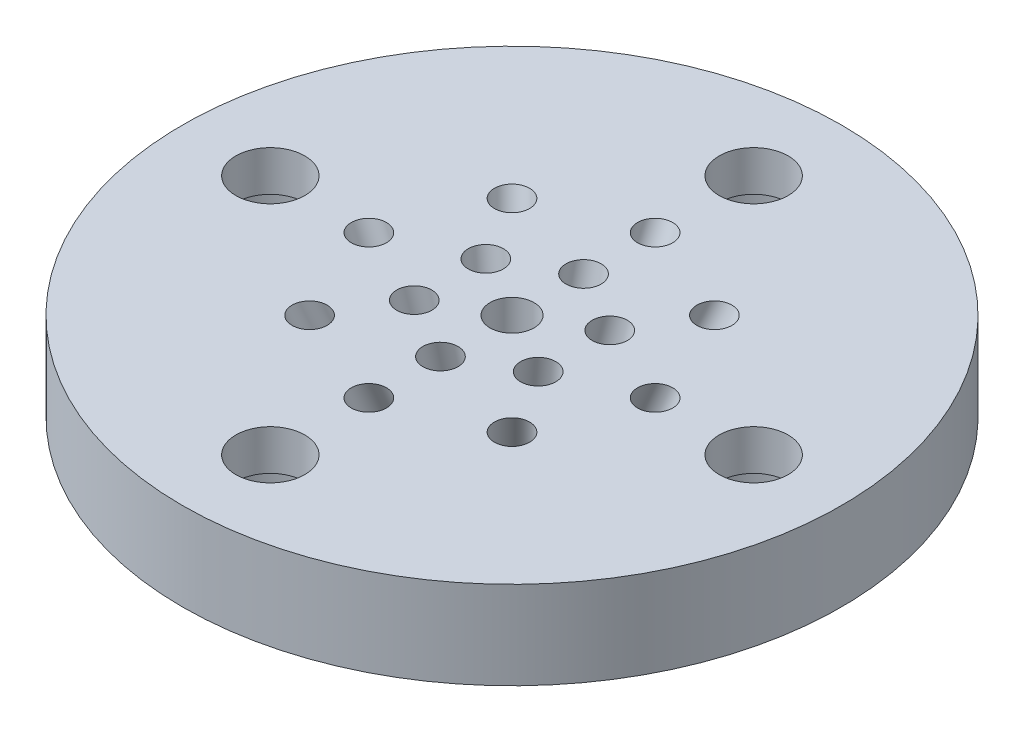
from build123d import *

# Parameters (mm, degrees)
SKETCH1_R                                           = 50.8
BOSS_EXTRUDE1_DEPTH                                 = 25.4
SKETCH2_R                                           = 69.85
SKETCH2_R_2                                         = 50.8
BOSS_EXTRUDE2_DEPTH                                 = 12.7
SKETCH3_R                                           = 49.53
SKETCH3_R_2                                         = 47.625
CUT_EXTRUDE1_DEPTH                                  = 1.1176
CUT_EXTRUDE2_REACH                                  = 103.996
SKETCH4_R                                           = 3.175
SKETCH5_R                                           = 11.43
CUT_EXTRUDE3_DEPTH                                  = 19.05
CUT_EXTRUDE4_REACH                                  = 102.603
SKETCH6_R                                           = 1.5875
SKETCH42_OUTSIDE_W                                  = 181.538
SKETCH42_OUTSIDE_H                                  = 181.538
SKETCH42_OUTSIDE_R                                  = 23.8125
CUT_EXTRUDE9_DEPTH                                  = 30.48
SKETCH43_R                                          = 20.6375
CUT_EXTRUDE10_DEPTH                                 = 19.05
CBORE_FOR_10_BINDING_HEAD_MACHINE_SCREW_D           = 4.9784
CBORE_FOR_10_BINDING_HEAD_MACHINE_SCREW_CBORE_D     = 9.525
CBORE_FOR_10_BINDING_HEAD_MACHINE_SCREW_CBORE_DEPTH = 3.429
CUT_EXTRUDE11_START                                 = -19.05
SKETCH52_R                                          = 23.8125
CUT_EXTRUDE11_DEPTH                                 = 19.05
SKETCH55_R                                          = 1.27
CUT_EXTRUDE12_DEPTH                                 = 7.62
CIRPATTERN1_COUNT                                   = 6
SKETCH57_R                                          = 1.27
CUT_EXTRUDE13_DEPTH                                 = 7.62
CIRPATTERN2_COUNT                                   = 8


with BuildPart() as part:
    # Sketch1 → Boss-Extrude1 (new body)
    with BuildSketch(Plane(origin=(0, 0, 0), x_dir=(1, 0, 0), z_dir=(0, 1, 0))):
        Circle(SKETCH1_R)
    extrude(amount=BOSS_EXTRUDE1_DEPTH)

    # Sketch2 → Boss-Extrude2 (add)
    with BuildSketch(Plane.XZ):
        Circle(SKETCH2_R)
        Circle(SKETCH2_R_2, mode=Mode.SUBTRACT)
    extrude(amount=-BOSS_EXTRUDE2_DEPTH)

    # Sketch3 → Cut-Extrude1 (cut)
    with BuildSketch(Plane.XZ):
        Circle(SKETCH3_R)
        Circle(SKETCH3_R_2, mode=Mode.SUBTRACT)
    extrude(amount=-CUT_EXTRUDE1_DEPTH, mode=Mode.SUBTRACT)

    # Sketch4 → Cut-Extrude2 (cut, up to next)
    with BuildSketch(Plane.XZ, mode=Mode.PRIVATE) as cut_extrude2_sk1:
        with Locations((0, -59.9186)):
            Circle(SKETCH4_R)
    cut_extrude2_tool1 = extrude(cut_extrude2_sk1.sketch, amount=-CUT_EXTRUDE2_REACH, mode=Mode.PRIVATE) & part.part
    # Sketch4 → Cut-Extrude2 (cut, up to next)
    with BuildSketch(Plane.XZ, mode=Mode.PRIVATE) as cut_extrude2_sk2:
        with Locations((-42.368848379, -42.368848379)):
            Circle(SKETCH4_R)
    cut_extrude2_tool2 = extrude(cut_extrude2_sk2.sketch, amount=-CUT_EXTRUDE2_REACH, mode=Mode.PRIVATE) & part.part
    # Sketch4 → Cut-Extrude2 (cut, up to next)
    with BuildSketch(Plane.XZ, mode=Mode.PRIVATE) as cut_extrude2_sk3:
        with Locations((-59.9186, 0)):
            Circle(SKETCH4_R)
    cut_extrude2_tool3 = extrude(cut_extrude2_sk3.sketch, amount=-CUT_EXTRUDE2_REACH, mode=Mode.PRIVATE) & part.part
    # Sketch4 → Cut-Extrude2 (cut, up to next)
    with BuildSketch(Plane.XZ, mode=Mode.PRIVATE) as cut_extrude2_sk4:
        with Locations((-42.368848379, 42.368848379)):
            Circle(SKETCH4_R)
    cut_extrude2_tool4 = extrude(cut_extrude2_sk4.sketch, amount=-CUT_EXTRUDE2_REACH, mode=Mode.PRIVATE) & part.part
    # Sketch4 → Cut-Extrude2 (cut, up to next)
    with BuildSketch(Plane.XZ, mode=Mode.PRIVATE) as cut_extrude2_sk5:
        with Locations((0, 59.9186)):
            Circle(SKETCH4_R)
    cut_extrude2_tool5 = extrude(cut_extrude2_sk5.sketch, amount=-CUT_EXTRUDE2_REACH, mode=Mode.PRIVATE) & part.part
    # Sketch4 → Cut-Extrude2 (cut, up to next)
    with BuildSketch(Plane.XZ, mode=Mode.PRIVATE) as cut_extrude2_sk6:
        with Locations((42.368848379, 42.368848379)):
            Circle(SKETCH4_R)
    cut_extrude2_tool6 = extrude(cut_extrude2_sk6.sketch, amount=-CUT_EXTRUDE2_REACH, mode=Mode.PRIVATE) & part.part
    # Sketch4 → Cut-Extrude2 (cut, up to next)
    with BuildSketch(Plane.XZ, mode=Mode.PRIVATE) as cut_extrude2_sk7:
        with Locations((59.9186, 0)):
            Circle(SKETCH4_R)
    cut_extrude2_tool7 = extrude(cut_extrude2_sk7.sketch, amount=-CUT_EXTRUDE2_REACH, mode=Mode.PRIVATE) & part.part
    # Sketch4 → Cut-Extrude2 (cut, up to next)
    with BuildSketch(Plane.XZ, mode=Mode.PRIVATE) as cut_extrude2_sk8:
        with Locations((42.368848379, -42.368848379)):
            Circle(SKETCH4_R)
    cut_extrude2_tool8 = extrude(cut_extrude2_sk8.sketch, amount=-CUT_EXTRUDE2_REACH, mode=Mode.PRIVATE) & part.part
    add(cut_extrude2_tool1.solids().sort_by_distance((0, 0, -59.9186))[0], mode=Mode.SUBTRACT)
    add(cut_extrude2_tool2.solids().sort_by_distance((-42.368848, 0, -42.368848))[0], mode=Mode.SUBTRACT)
    add(cut_extrude2_tool3.solids().sort_by_distance((-59.9186, 0, 0))[0], mode=Mode.SUBTRACT)
    add(cut_extrude2_tool4.solids().sort_by_distance((-42.368848, 0, 42.368848))[0], mode=Mode.SUBTRACT)
    add(cut_extrude2_tool5.solids().sort_by_distance((0, 0, 59.9186))[0], mode=Mode.SUBTRACT)
    add(cut_extrude2_tool6.solids().sort_by_distance((42.368848, 0, 42.368848))[0], mode=Mode.SUBTRACT)
    add(cut_extrude2_tool7.solids().sort_by_distance((59.9186, 0, 0))[0], mode=Mode.SUBTRACT)
    add(cut_extrude2_tool8.solids().sort_by_distance((42.368848, 0, -42.368848))[0], mode=Mode.SUBTRACT)

    # Sketch5 → Cut-Extrude3 (cut)
    with BuildSketch(Plane(origin=(0, 25.4, 0), x_dir=(1, 0, 0), z_dir=(0, 1, 0))):
        Circle(SKETCH5_R)
    extrude(amount=-CUT_EXTRUDE3_DEPTH, mode=Mode.SUBTRACT)

    # Sketch6 → Cut-Extrude4 (cut, up to next)
    with BuildSketch(Plane(origin=(0, 6.35, 0), x_dir=(1, 0, 0), z_dir=(0, 1, 0)), mode=Mode.PRIVATE) as cut_extrude4_sk1:
        Circle(SKETCH6_R)
    cut_extrude4_tool1 = extrude(cut_extrude4_sk1.sketch, amount=-CUT_EXTRUDE4_REACH, mode=Mode.PRIVATE) & part.part
    add(cut_extrude4_tool1.solids().sort_by_distance((0, 6.35, 0))[0], mode=Mode.SUBTRACT)

    # Sketch42 outside → Cut-Extrude9 (cut)
    with BuildSketch(Plane.XZ):
        Rectangle(SKETCH42_OUTSIDE_W, SKETCH42_OUTSIDE_H)
        Circle(SKETCH42_OUTSIDE_R, mode=Mode.SUBTRACT)
    extrude(amount=-CUT_EXTRUDE9_DEPTH, mode=Mode.SUBTRACT)

    # Sketch43 → Cut-Extrude10 (cut)
    with BuildSketch(Plane(origin=(0, 25.4, 0), x_dir=(1, 0, 0), z_dir=(0, 1, 0))):
        Circle(SKETCH43_R)
    extrude(amount=-CUT_EXTRUDE10_DEPTH, mode=Mode.SUBTRACT)

    # CBORE for _10 Binding Head Machine Screw (through all)
    with Locations(Plane(origin=(0, 0, 0), x_dir=(-1, 0, 0), z_dir=(0, -1, 0))):
        with Locations((0, -17.4625), (-17.4625, 0), (17.4625, 0), (0, 17.4625)):
            CounterBoreHole(CBORE_FOR_10_BINDING_HEAD_MACHINE_SCREW_D / 2, CBORE_FOR_10_BINDING_HEAD_MACHINE_SCREW_CBORE_D / 2, CBORE_FOR_10_BINDING_HEAD_MACHINE_SCREW_CBORE_DEPTH)

    # Sketch52 → Cut-Extrude11 (cut)
    with BuildSketch(Plane(origin=(0, 25.4, 0), x_dir=(1, 0, 0), z_dir=(0, 1, 0)).offset(CUT_EXTRUDE11_START)):
        Circle(SKETCH52_R)
    extrude(amount=CUT_EXTRUDE11_DEPTH, mode=Mode.SUBTRACT)

    # Sketch55 → Cut-Extrude12 (cut, along a direction that is not the sketch's normal)
    with BuildSketch(Plane.XZ):
        with Locations((0, 3.81)):
            Circle(SKETCH55_R)
    cut_extrude12 = extrude(amount=-CUT_EXTRUDE12_DEPTH, dir=(0, -0.9778024140774095, -0.2095290887308735), mode=Mode.SUBTRACT)

    # CirPattern1: Cut-Extrude12 ×6 about axis
    cirpattern1_axis = Axis((0, 0, 0), (0, -1, 0))
    for i in range(1, CIRPATTERN1_COUNT):
        add(cut_extrude12.rotate(cirpattern1_axis, i * 360 / CIRPATTERN1_COUNT), mode=Mode.SUBTRACT)

    # Sketch57 → Cut-Extrude13 (cut, along a direction that is not the sketch's normal)
    with BuildSketch(Plane.XZ):
        with Locations((0, 7.62)):
            Circle(SKETCH57_R)
    cut_extrude13 = extrude(amount=-CUT_EXTRUDE13_DEPTH, dir=(0, -0.9191450300180579, -0.39391929857916774), mode=Mode.SUBTRACT)

    # CirPattern2: Cut-Extrude13 ×8 about axis
    cirpattern2_axis = Axis((0, 0, 0), (0, -1, 0))
    for i in range(1, CIRPATTERN2_COUNT):
        add(cut_extrude13.rotate(cirpattern2_axis, i * 360 / CIRPATTERN2_COUNT), mode=Mode.SUBTRACT)


solid = part.part
